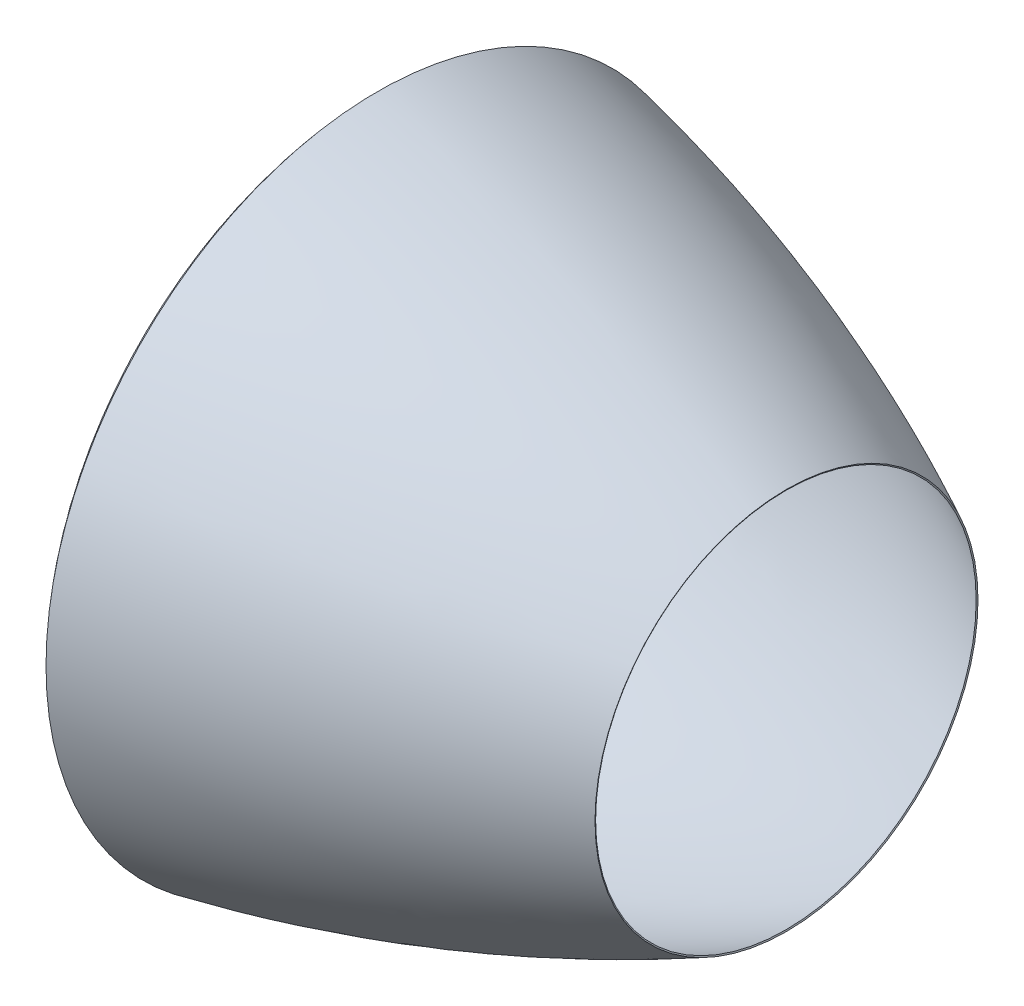
from build123d import *

# Parameters (mm, degrees)
THICKEN1_T1 = 5


with BuildPart() as body_1:
    # Surface-Revolve1: a surface, the sketch's curves turned about an axis
    with BuildLine(Plane.XY, mode=Mode.PRIVATE) as surface_revolve1_1_path:
        Line((130, 1050), (80, 1050))
        Line((80, 1050), (80, 1000))
        Line((80, 1000), (0, 1000))
        add(Edge.make_bspline(
            [(0, 1000), (-101.166130319, 1106.131945773), (0, 1214.671550025)],
            knots=[0, 0, 0, 1, 1, 1], degree=2))
        add(Edge.make_bspline(
            [(0, 1214.671550025), (784.002803611, 1057.950167401), (1500, 700)],
            knots=[0, 0, 0, 1, 1, 1], degree=2))
    surface_revolve1_1 = Shell.revolve(surface_revolve1_1_path.wire(), 360, Axis((0, 0, 0), (1, 0, 0)))
    add(Solid.thicken(surface_revolve1_1, THICKEN1_T1))


solid = body_1.part
